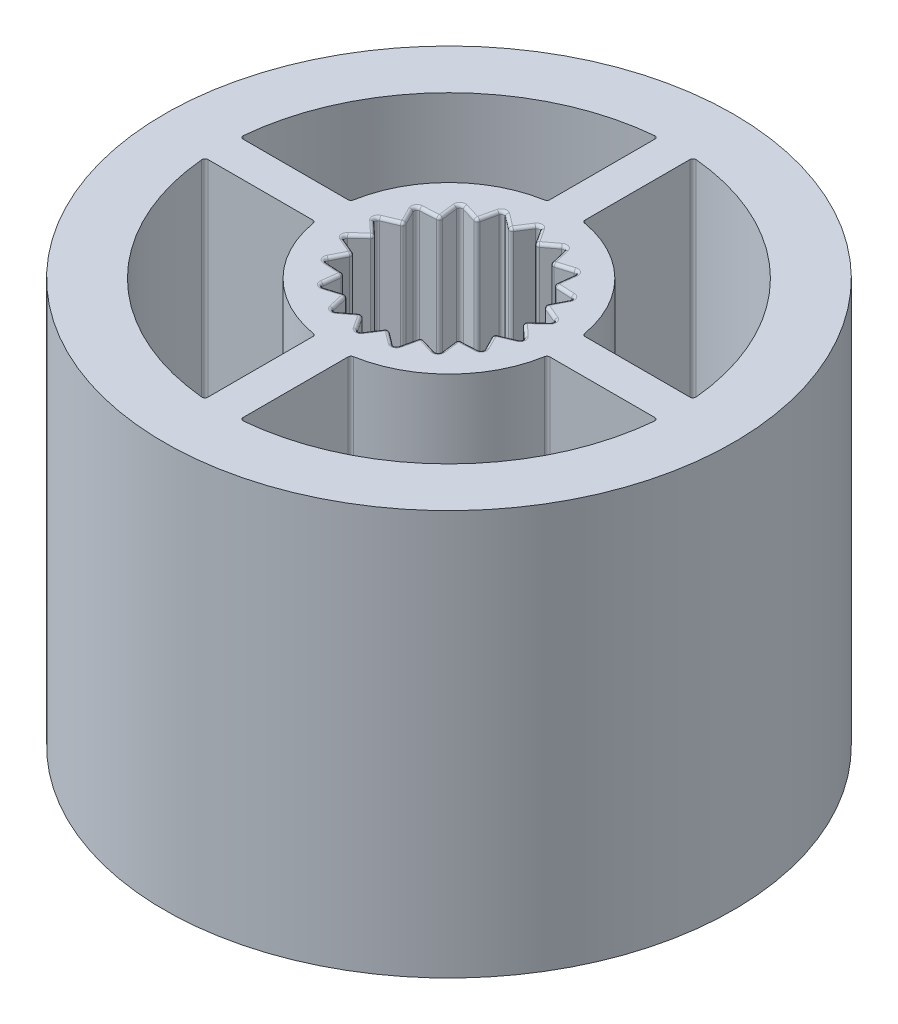
from build123d import *

# Parameters (mm, degrees)
SKETCH1_R               = 10
BOSS_EXTRUDE1_DEPTH     = 16.8
SKETCH8_R               = 9.7
CUT_EXTRUDE4_DEPTH      = 16.3
SKETCH12_R              = 9.7
SKETCH12_R_2            = 7.75
BOSS_EXTRUDE6_DEPTH     = 13.8
SKETCH10_R              = 4
BOSS_EXTRUDE4_DEPTH     = 12.8
SKETCH11_W              = 4.957864705
SKETCH11_H              = 1.2
SKETCH11_W_2            = 1.2
SKETCH11_H_2            = 4.957864705
BOSS_EXTRUDE5_DEPTH     = 12.3
SKETCH16_W              = 20
SKETCH16_H              = 22.025031377
CUT_EXTRUDE5_DEPTH      = 11
CUT_EXTRUDE5_DEPTH_BACK = 11
FILLET1_R               = 0.1


with BuildPart() as part:
    # Sketch1 → Boss-Extrude1 (new body)
    with BuildSketch(Plane(origin=(0, 0, 0), x_dir=(1, 0, 0), z_dir=(0, 1, 0))):
        Circle(SKETCH1_R)
    extrude(amount=BOSS_EXTRUDE1_DEPTH)

    # Sketch8 → Cut-Extrude4 (cut)
    with BuildSketch(Plane.XZ):
        Circle(SKETCH8_R)
    extrude(amount=-CUT_EXTRUDE4_DEPTH, mode=Mode.SUBTRACT)

    # Sketch16 → Cut-Extrude5 (cut, two sides)
    with BuildSketch(Plane.XY) as cut_extrude5_sk:
        with Locations((0, 11.012515689)):
            Rectangle(SKETCH16_W, SKETCH16_H)
    extrude(amount=CUT_EXTRUDE5_DEPTH, mode=Mode.SUBTRACT)
    extrude(cut_extrude5_sk.sketch, amount=-CUT_EXTRUDE5_DEPTH_BACK, mode=Mode.SUBTRACT)


with BuildPart() as body_2:
    # Sketch12 → Boss-Extrude6 (new body)
    with BuildSketch(Plane.XZ):
        Circle(SKETCH12_R)
        Circle(SKETCH12_R_2, mode=Mode.SUBTRACT)
    extrude(amount=BOSS_EXTRUDE6_DEPTH)



with BuildPart() as body_3:
    # Sketch10 → Boss-Extrude4 (new body)
    with BuildSketch(Plane.XZ):
        Circle(SKETCH10_R)
        Polygon((0, 3.167239607), (0.439078531, 2.490138093), (1.083259744, 2.976231687), (1.264276243, 2.189790688), (2.035862376, 2.426246301), (1.936983582, 1.625322209), (2.74290996, 1.583619804), (2.376062113, 0.864815884), (3.119122121, 0.549985386), (2.528552487, 0), (3.119122121, -0.549985386), (2.376062113, -0.864815884), (2.74290996, -1.583619804), (1.936983582, -1.625322209), (2.035862376, -2.426246301), (1.264276243, -2.189790688), (1.083259744, -2.976231687), (0.439078531, -2.490138093), (0, -3.167239607), (-0.439078531, -2.490138093), (-1.083259744, -2.976231687), (-1.264276243, -2.189790688), (-2.035862376, -2.426246301), (-1.936983582, -1.625322209), (-2.74290996, -1.583619804), (-2.376062113, -0.864815884), (-3.119122121, -0.549985386), (-2.528552487, 0), (-3.119122121, 0.549985386), (-2.376062113, 0.864815884), (-2.74290996, 1.583619804), (-1.936983582, 1.625322209), (-2.035862376, 2.426246301), (-1.264276243, 2.189790688), (-1.083259744, 2.976231687), (-0.439078531, 2.490138093), align=None, mode=Mode.SUBTRACT)
    extrude(amount=BOSS_EXTRUDE4_DEPTH)


with BuildPart() as body_2_1:
    add(body_2.part)

    add(body_3.part)  # Boss-Extrude5 merges body 3
    # Sketch11 → Boss-Extrude5 (add)
    with BuildSketch(Plane.XZ):
        with Locations((5.788570759, 0)):
            Rectangle(SKETCH11_W, SKETCH11_H)
        with Locations((0, 5.788570759)):
            Rectangle(SKETCH11_W_2, SKETCH11_H_2)
        with Locations((0, -5.788570759)):
            Rectangle(SKETCH11_W_2, SKETCH11_H_2)
        with Locations((-5.788570759, 0)):
            Rectangle(SKETCH11_W, SKETCH11_H)
    extrude(amount=BOSS_EXTRUDE5_DEPTH)

    # Fillet1
    fillet1_edges = [body_2_1.edges().sort_by_distance(p)[0] for p in [
        (-2.376062113, -6.4, -0.864815884),
        (-2.74290996, -6.4, -1.583619804),
        (-1.936983582, -6.4, -1.625322209),
        (-2.035862376, -6.4, -2.426246301),
        (-1.264276243, -6.4, -2.189790688),
        (-1.083259744, -6.4, -2.976231687),
        (-0.439078531, -6.4, -2.490138093),
        (0, -6.4, -3.167239607),
        (0.439078531, -6.4, -2.490138093),
        (1.083259744, -6.4, -2.976231687),
        (1.264276243, -6.4, -2.189790688),
        (2.035862376, -6.4, -2.426246301),
        (1.936983582, -6.4, -1.625322209),
        (2.74290996, -6.4, -1.583619804),
        (2.376062113, -6.4, -0.864815884),
        (3.119122121, -6.4, -0.549985386),
        (2.528552487, -6.4, 0),
        (3.119122121, -6.4, 0.549985386),
        (2.376062113, -6.4, 0.864815884),
        (2.74290996, -6.4, 1.583619804),
        (1.936983582, -6.4, 1.625322209),
        (2.035862376, -6.4, 2.426246301),
        (1.264276243, -6.4, 2.189790688),
        (1.083259744, -6.4, 2.976231687),
        (0.439078531, -6.4, 2.490138093),
        (0.219539266, -12.8, 2.82868885),
        (1.173767994, -12.8, 2.583011188),
        (1.986422979, -12.8, 2.025784255),
        (2.559486036, -12.8, 1.224217844),
        (2.823837304, -12.8, 0.274992693),
        (2.747592117, -12.8, -0.707400635),
        (2.339946771, -12.8, -1.604471006),
        (1.65006931, -12.8, -2.308018495),
        (0.761169138, -12.8, -2.73318489),
        (-0.219539266, -12.8, -2.82868885),
        (-1.173767994, -12.8, -2.583011188),
        (-1.986422979, -12.8, -2.025784255),
        (-2.559486036, -12.8, -1.224217844),
        (-2.823837304, -12.8, -0.274992693),
        (-2.747592117, -12.8, 0.707400635),
        (-2.339946771, -12.8, 1.604471006),
        (-1.65006931, -12.8, 2.308018495),
        (-0.761169138, -12.8, 2.73318489),
        (-1.173767994, -12.8, 2.583011188),
        (-1.986422979, -12.8, 2.025784255),
        (-2.559486036, -12.8, 1.224217844),
        (-2.823837304, -12.8, 0.274992693),
        (-2.747592117, -12.8, -0.707400635),
        (-2.339946771, -12.8, -1.604471006),
        (-1.65006931, -12.8, -2.308018495),
        (-0.761169138, -12.8, -2.73318489),
        (0.219539266, -12.8, -2.82868885),
        (1.173767994, -12.8, -2.583011188),
        (1.986422979, -12.8, -2.025784255),
        (2.559486036, -12.8, -1.224217844),
        (2.823837304, -12.8, -0.274992693),
        (2.747592117, -12.8, 0.707400635),
        (2.339946771, -12.8, 1.604471006),
        (1.65006931, -12.8, 2.308018495),
        (0.761169138, -12.8, 2.73318489),
        (-4, -12.8, 0),
        (0, -12.3, 4),
        (0.6, -6.15, 3.954743987),
        (-0.6, -6.15, 3.954743987),
        (0.6, -12.3, 5.840741637),
        (-0.6, -12.3, 5.840741637),
        (0, -12.3, 7.75),
        (0.6, -6.15, 7.726739286),
        (-0.6, -6.15, 7.726739286),
        (7.744182638, -12.3, 0.300225357),
        (7.726739286, -6.15, 0.6),
        (7.726739286, -6.15, -0.6),
        (3.954743987, -6.15, -0.6),
        (3.954743987, -6.15, 0.6),
        (3.98866995, -12.3, 0.300852167),
        (5.840741637, -12.3, -0.6),
        (5.840741637, -12.3, 0.6),
        (0, -12.3, -7.75),
        (0, -12.3, -4),
        (-0.6, -12.3, -5.840741637),
        (0.6, -12.3, -5.840741637),
        (-0.6, -6.15, -3.954743987),
        (-0.6, -6.15, -7.726739286),
        (0.6, -6.15, -3.954743987),
        (0.6, -6.15, -7.726739286),
        (-7.75, -12.3, 0),
        (-4, -12.3, 0),
        (-5.840741637, -12.3, 0.6),
        (-5.840741637, -12.3, -0.6),
        (-3.954743987, -6.15, 0.6),
        (-7.726739286, -6.15, 0.6),
        (-3.954743987, -6.15, -0.6),
        (-7.726739286, -6.15, -0.6),
        (0.761169138, 0, 2.73318489),
        (1.173767994, 0, 2.583011188),
        (1.65006931, 0, 2.308018495),
        (1.986422979, 0, 2.025784255),
        (2.339946771, 0, 1.604471006),
        (2.559486036, 0, 1.224217844),
        (2.747592117, 0, 0.707400635),
        (2.823837304, 0, 0.274992693),
        (2.823837304, 0, -0.274992693),
        (2.747592117, 0, -0.707400635),
        (2.559486036, 0, -1.224217844),
        (2.339946771, 0, -1.604471006),
        (1.986422979, 0, -2.025784255),
        (1.65006931, 0, -2.308018495),
        (1.173767994, 0, -2.583011188),
        (0.761169138, 0, -2.73318489),
        (0.219539266, 0, -2.82868885),
        (-0.219539266, 0, -2.82868885),
        (-0.761169138, 0, -2.73318489),
        (-1.173767994, 0, -2.583011188),
        (-1.65006931, 0, -2.308018495),
        (-1.986422979, 0, -2.025784255),
        (-2.339946771, 0, -1.604471006),
        (-2.559486036, 0, -1.224217844),
        (-2.747592117, 0, -0.707400635),
        (-2.823837304, 0, -0.274992693),
        (-2.823837304, 0, 0.274992693),
        (-2.747592117, 0, 0.707400635),
        (-2.559486036, 0, 1.224217844),
        (-2.339946771, 0, 1.604471006),
        (-1.986422979, 0, 2.025784255),
        (-1.65006931, 0, 2.308018495),
        (-1.173767994, 0, 2.583011188),
        (-0.761169138, 0, 2.73318489),
        (-0.219539266, 0, 2.82868885),
        (0.219539266, 0, 2.82868885),
        (0, -6.4, 3.167239607),
        (-0.439078531, -6.4, 2.490138093),
        (-0.219539266, -12.8, 2.82868885),
        (-1.083259744, -6.4, 2.976231687),
        (-1.264276243, -6.4, 2.189790688),
        (-2.035862376, -6.4, 2.426246301),
        (-1.936983582, -6.4, 1.625322209),
        (-2.74290996, -6.4, 1.583619804),
        (-2.376062113, -6.4, 0.864815884),
        (-3.119122121, -6.4, 0.549985386),
        (-2.528552487, -6.4, 0),
        (-3.119122121, -6.4, -0.549985386),
    ]]
    fillet(fillet1_edges, radius=FILLET1_R)


solid = body_2_1.part
